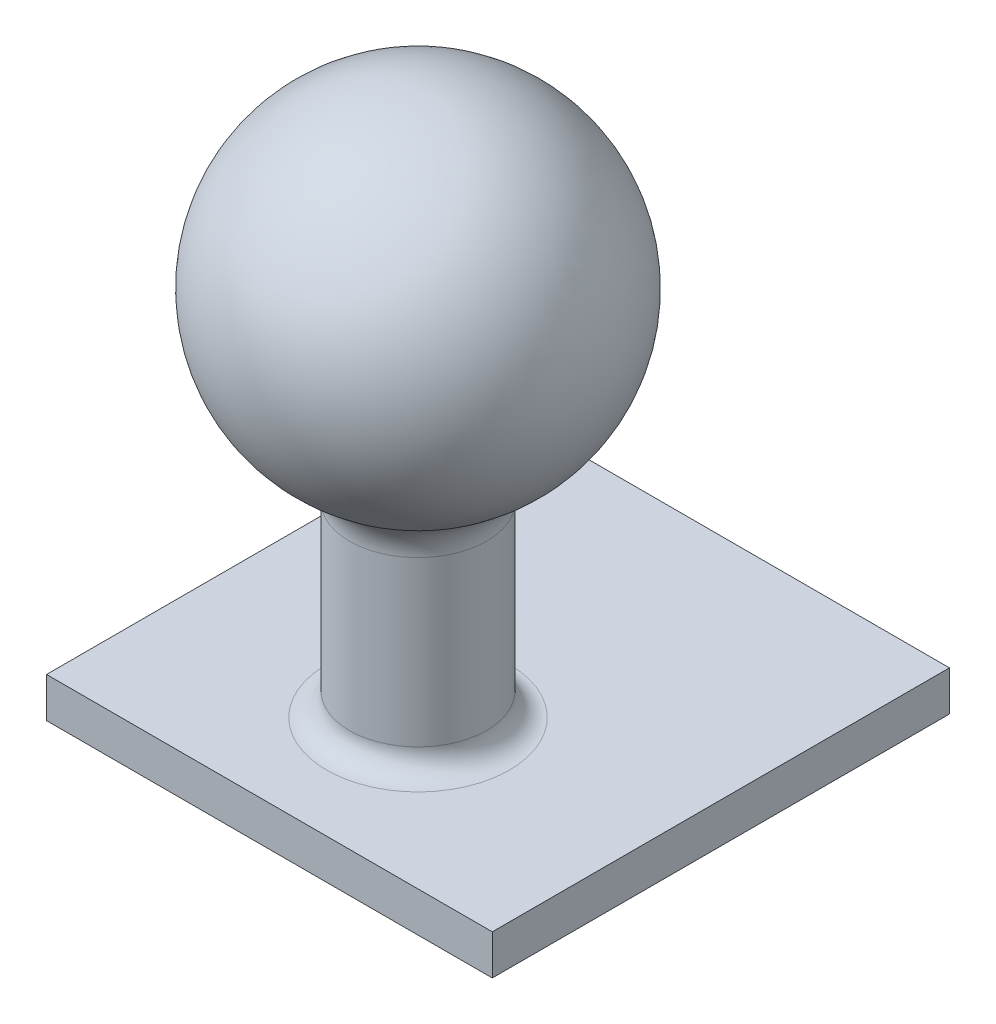
from build123d import *

# Parameters (mm, degrees)
SKETCH2_W           = 19.5
SKETCH2_H           = 20
BOSS_EXTRUDE1_DEPTH = 1.75
SKETCH3_W           = 19.5
SKETCH3_H           = 3.5
CUT_EXTRUDE1_DEPTH  = 2.75
SKETCH4_W           = 19.5
SKETCH4_H           = 1.75
BOSS_EXTRUDE2_DEPTH = 3.5
FILLET1_R           = 2
FILLET2_R           = 1


with BuildPart() as part:
    # Sketch1 → Revolve1 (revolve)
    with BuildSketch(Plane(origin=(0, 0, 0), x_dir=(0, 0, -1), z_dir=(1, 0, 0))):
        with BuildLine():
            Line((3, -6.873863542), (3, -16.25))
            Line((3, -16.25), (6, -16.25))
            Line((6, -16.25), (6, -18))
            Line((6, -18), (0, -18))
            Line((0, -18), (0, -7.5))
            Line((0, -7.5), (0, 7.5))
            ThreePointArc((0, 7.5), (7.341797347, 1.532322328), (3, -6.873863542))
        make_face()
    revolve(axis=Axis((0, 0, 0), (0, -1, 0)))

    # Sketch2 → Boss-Extrude1 (add)
    with BuildSketch(Plane.XZ.offset(18)):
        Rectangle(SKETCH2_W, SKETCH2_H)
    extrude(amount=-BOSS_EXTRUDE1_DEPTH)

    # Sketch3 → Cut-Extrude1 (cut, through all)
    with BuildSketch(Plane(origin=(0, -16.25, 0), x_dir=(1, 0, 0), z_dir=(0, 1, 0))):
        with Locations((0, -8.25)):
            Rectangle(SKETCH3_W, SKETCH3_H)
    extrude(amount=-CUT_EXTRUDE1_DEPTH, mode=Mode.SUBTRACT)

    # Sketch4 → Boss-Extrude2 (add)
    with BuildSketch(Plane(origin=(0, 0, -10), x_dir=(-1, 0, 0), z_dir=(0, 0, -1))):
        with Locations((0, -17.125)):
            Rectangle(SKETCH4_W, SKETCH4_H)
    extrude(amount=BOSS_EXTRUDE2_DEPTH)

    # Fillet1
    fillet1_edges = [part.edges().sort_by_distance(p)[0] for p in [
        (0, -6.873863542, 3),
    ]]
    fillet(fillet1_edges, radius=FILLET1_R)

    # Fillet2
    fillet2_edges = [part.edges().sort_by_distance(p)[0] for p in [
        (0, -16.25, 3),
    ]]
    fillet(fillet2_edges, radius=FILLET2_R)


solid = part.part
